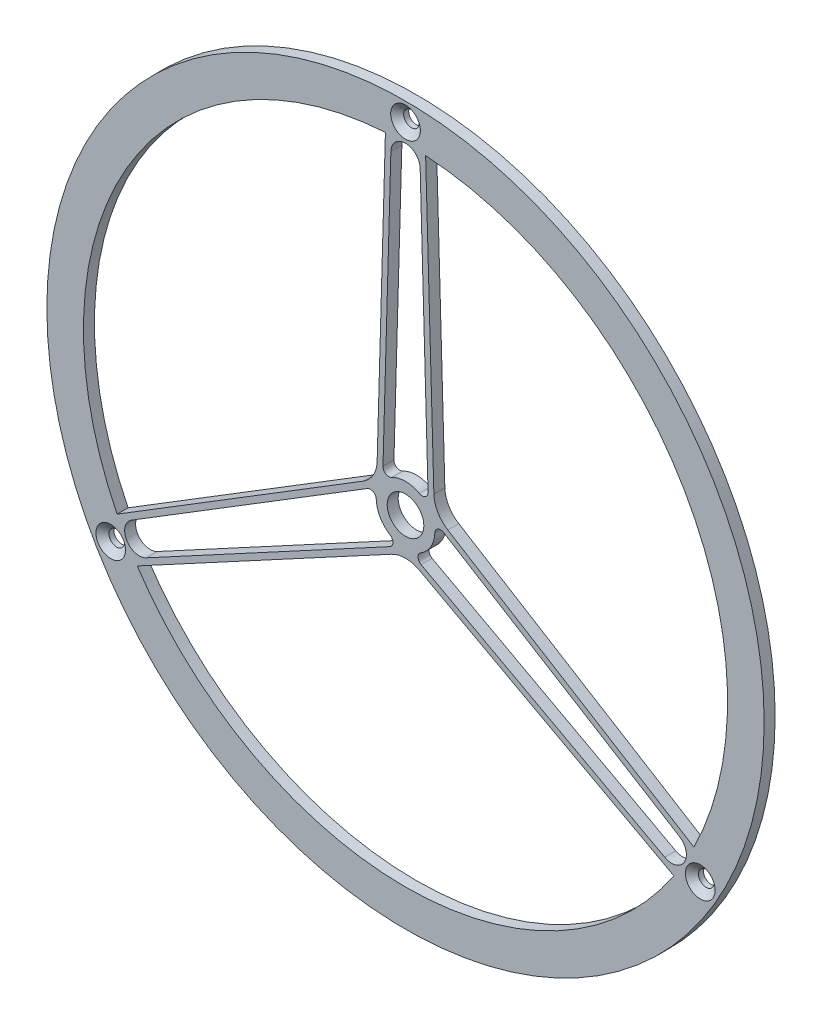
from build123d import *

# Parameters (mm, degrees)
SKETCH1_R                                   = 155.575
SKETCH1_R_2                                 = 7.9375
BOSS_EXTRUDE1_DEPTH                         = 4.7625
FILLET1_R                                   = 12.7
FILLET4_R                                   = 2.54
CSK_FOR_1_4_FLAT_HEAD_MACHINE_SCREW_2_COUNT = 2
CSK_FOR_1_4_FLAT_HEAD_MACHINE_SCREW_2_PITCH = 255.715651102
CSK_FOR_1_4_FLAT_HEAD_MACHINE_SCREW_3_COUNT = 2
CSK_FOR_1_4_FLAT_HEAD_MACHINE_SCREW_3_PITCH = 255.715651102


with BuildPart() as part:
    # Sketch1 → Boss-Extrude1 (new body)
    with BuildSketch(Plane.XY):
        Circle(SKETCH1_R)
        with BuildLine():
            ThreePointArc((-125.107792883, -62.16212802), (-120.983748909, 69.85), (-8.719914422, 139.427590858))
            Line((-8.719914422, 139.427590858), (-12.49892387, 7.216257061))
            Line((-12.49892387, 7.216257061), (-125.107792883, -62.16212802))
        make_face(mode=Mode.SUBTRACT)
        with BuildLine():
            ThreePointArc((8.719914422, 139.427590858), (120.983748909, 69.85), (125.107792883, -62.16212802))
            Line((125.107792883, -62.16212802), (12.49892387, 7.216257061))
            Line((12.49892387, 7.216257061), (8.719914422, 139.427590858))
        make_face(mode=Mode.SUBTRACT)
        with BuildLine():
            ThreePointArc((116.38787846, -77.265462838), (0, -139.7), (-116.38787846, -77.265462838))
            Line((-116.38787846, -77.265462838), (0, -14.432514122))
            Line((0, -14.432514122), (116.38787846, -77.265462838))
        make_face(mode=Mode.SUBTRACT)
        with BuildLine():
            Line((-12.585726429, 4.179407795), (-12.694815268, 0.362857143))
            ThreePointArc((-12.694815268, 0.362857143), (-10.998522628, -6.35), (-6.03316413, -11.17546109))
            Line((-6.03316413, -11.17546109), (-2.673389891, -12.98926271))
            Line((-2.673389891, -12.98926271), (-112.467905529, -72.262730545))
            ThreePointArc((-112.467905529, -72.262730545), (-120.983748909, -69.85), (-118.815313164, -61.268698026))
            Line((-118.815313164, -61.268698026), (-12.585726429, 4.179407795))
        make_face(mode=Mode.SUBTRACT)
        with BuildLine():
            ThreePointArc((118.815313164, -61.268698026), (120.983748909, -69.85), (112.467905529, -72.262730545))
            Line((112.467905529, -72.262730545), (2.673389891, -12.98926271))
            Line((2.673389891, -12.98926271), (6.03316413, -11.17546109))
            ThreePointArc((6.03316413, -11.17546109), (10.998522628, -6.35), (12.694815268, 0.362857143))
            Line((12.694815268, 0.362857143), (12.585726429, 4.179407795))
            Line((12.585726429, 4.179407795), (118.815313164, -61.268698026))
        make_face(mode=Mode.SUBTRACT)
        Circle(SKETCH1_R_2, mode=Mode.SUBTRACT)
        with BuildLine():
            ThreePointArc((-6.347407634, 133.531428571), (0, 139.7), (6.347407634, 133.531428571))
            Line((6.347407634, 133.531428571), (9.938137929, 7.907174875))
            ThreePointArc((9.938137929, 7.907174875), (0, 12.7), (-9.938137929, 7.907174875))
            Line((-9.938137929, 7.907174875), (-6.347407634, 133.531428571))
        make_face(mode=Mode.SUBTRACT)
    extrude(amount=-BOSS_EXTRUDE1_DEPTH)

    # Fillet1
    fillet1_edges = [part.edges().sort_by_distance(p)[0] for p in [
        (12.49892387, 7.216257061, -2.38125),
        (0, -14.432514122, -2.38125),
        (-12.49892387, 7.216257061, -2.38125),
    ]]
    fillet(fillet1_edges, radius=FILLET1_R)

    # Fillet4
    fillet4_edges = [part.edges().sort_by_distance(p)[0] for p in [
        (12.585726429, 4.179407795, -2.38125),
        (2.673389891, -12.98926271, -2.38125),
        (-2.673389891, -12.98926271, -2.38125),
        (-12.585726429, 4.179407795, -2.38125),
        (-9.938137929, 7.907174875, -2.38125),
        (9.938137929, 7.907174875, -2.38125),
    ]]
    fillet(fillet4_edges, radius=FILLET4_R)

    # Sketch4 → CSK for 1/4 Flat Head Machine Screw (100)1 (revolve, cut)
    with BuildSketch(Plane(origin=(0, 147.6375, 0), x_dir=(0, -1, 0), z_dir=(1, 0, 0))):
        Polygon((0, 0), (0, 4.7625), (3.3782, 4.7625), (3.3782, 2.568232241), (6.4389, 0), align=None)
    csk_for_1_4_flat_head_machine_screw_100 = revolve(axis=Axis((0, 147.6375, 6.35), (0, 0, -1)), mode=Mode.SUBTRACT)

    # CSK for 1_4 Flat Head Machine Screw  2: CSK for 1/4 Flat Head Machine Screw (100)1 ×2
    with Locations(*[Vector(0.5, -0.866025404, 0) * (i * CSK_FOR_1_4_FLAT_HEAD_MACHINE_SCREW_2_PITCH) for i in range(1, CSK_FOR_1_4_FLAT_HEAD_MACHINE_SCREW_2_COUNT)]):
        add(csk_for_1_4_flat_head_machine_screw_100, mode=Mode.SUBTRACT)

    # CSK for 1_4 Flat Head Machine Screw  3: CSK for 1/4 Flat Head Machine Screw (100)1 ×2
    with Locations(*[Vector(-0.5, -0.866025404, 0) * (i * CSK_FOR_1_4_FLAT_HEAD_MACHINE_SCREW_3_PITCH) for i in range(1, CSK_FOR_1_4_FLAT_HEAD_MACHINE_SCREW_3_COUNT)]):
        add(csk_for_1_4_flat_head_machine_screw_100, mode=Mode.SUBTRACT)


solid = part.part
